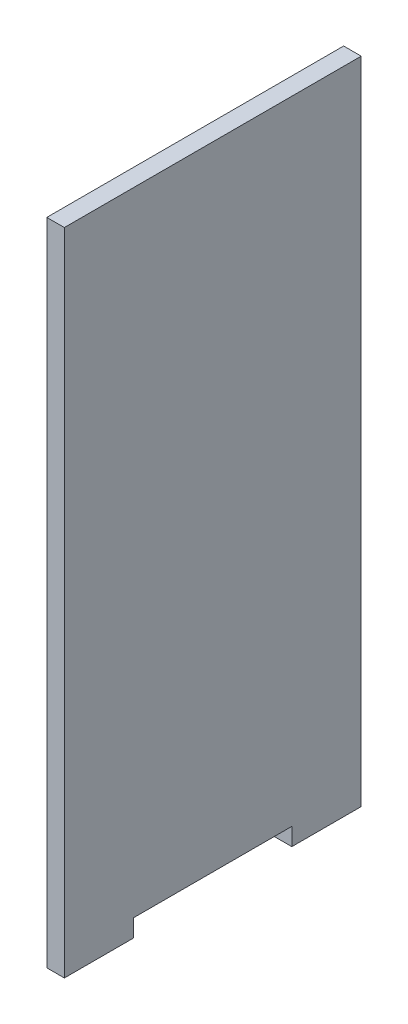
from build123d import *

# Parameters (mm, degrees)
BOSS_EXTRUDE1_DEPTH = 5


with BuildPart() as part:
    # Sketch1 → Boss-Extrude1 (new body)
    with BuildSketch(Plane(origin=(0, 0, 0), x_dir=(0, 0, -1), z_dir=(1, 0, 0))):
        Polygon((-42.25, 180), (42.25, 180), (42.25, 0), (42.25, -5), (22.5, -5), (22.5, 0), (-22.5, 0), (-22.5, -5), (-42.25, -5), (-42.25, 0), align=None)
    extrude(amount=BOSS_EXTRUDE1_DEPTH)


solid = part.part
